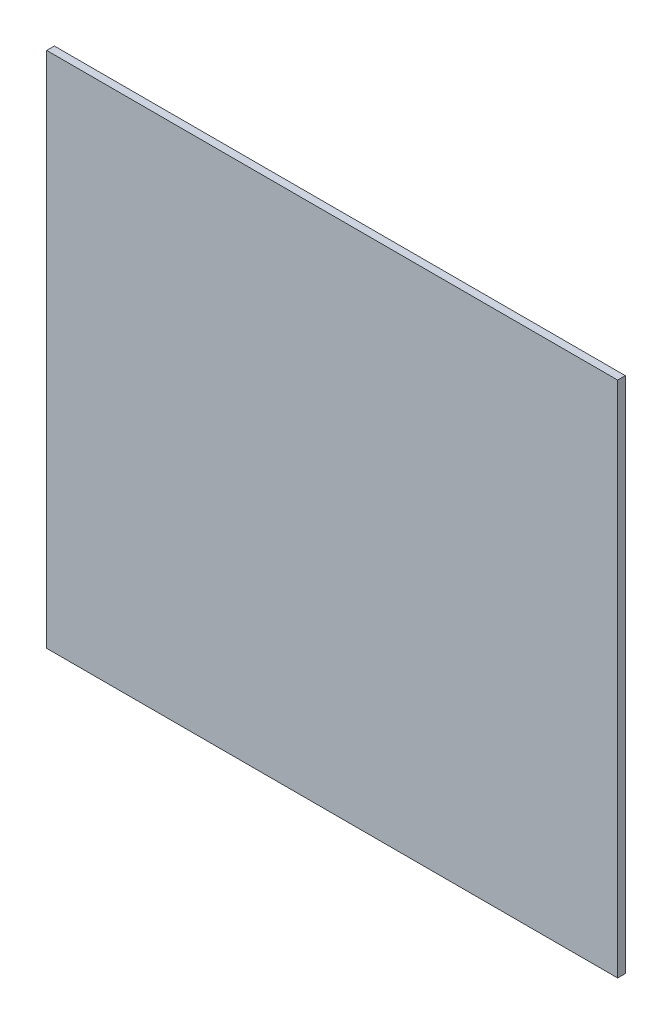
from build123d import *

# Parameters (mm, degrees)
SKETCH1_W           = 323.85
SKETCH1_H           = 293.7256
BOSS_EXTRUDE1_DEPTH = 4.3434


with BuildPart() as part:
    # Sketch1 → Boss-Extrude1 (new body)
    with BuildSketch(Plane.XY):
        Rectangle(SKETCH1_W, SKETCH1_H)
    extrude(amount=BOSS_EXTRUDE1_DEPTH)


solid = part.part
